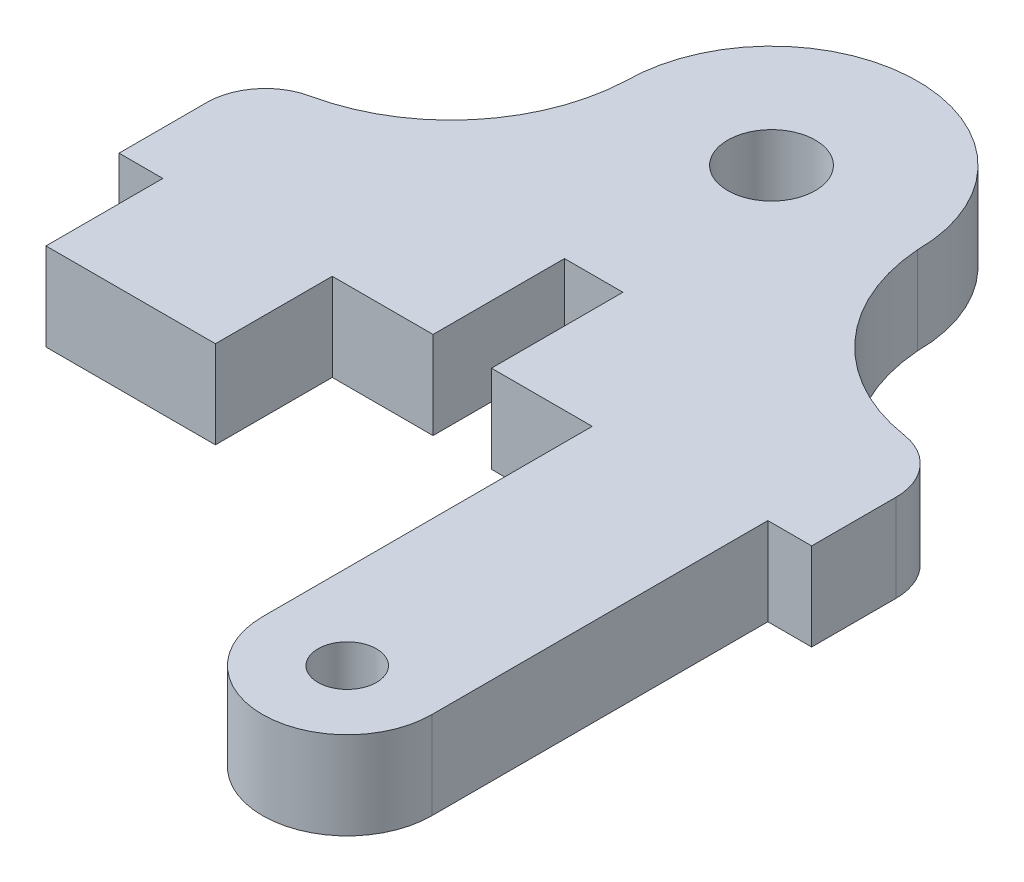
from build123d import *

# Parameters (mm, degrees)
BOSS_EXTRUDE1_DEPTH = 3
SKETCH3_R           = 1.5
CUT_EXTRUDE1_DEPTH  = 3
FILLET1_R           = 2
SKETCH4_R           = 1
CUT_EXTRUDE2_DEPTH  = 10


with BuildPart() as part:
    # Sketch2 → Boss-Extrude1 (new body)
    with BuildSketch(Plane(origin=(0, 0, 0), x_dir=(1, 0, 0), z_dir=(0, 1, 0))):
        with BuildLine():
            Line((4.668611776, -14.59443044), (4.668611776, -22.09443044))
            ThreePointArc((4.668611776, -22.09443044), (7.568611776, -24.99443044), (10.468611776, -22.09443044))
            Line((10.468611776, -22.09443044), (10.468611776, -14.59443044))
            Line((10.468611776, -14.59443044), (10.468611776, -10.59443044))
            Line((10.468611776, -10.59443044), (11.968611776, -10.59443044))
            Line((11.968611776, -10.59443044), (11.968611776, -5.761851858))
            ThreePointArc((11.968611776, -5.761851858), (7.254363967, -4.368466387), (5, 0))
            ThreePointArc((5, 0), (0, 5), (-5, 0))
            ThreePointArc((-5, 0), (-7.028472422, -4.339612176), (-11.531388224, -5.973834769))
            Line((-11.531388224, -5.973834769), (-11.531388224, -10.806413351))
            Line((-11.531388224, -10.806413351), (-10.031388224, -10.806413351))
            Line((-10.031388224, -10.806413351), (-10.031388224, -14.806413351))
            Line((-10.031388224, -14.806413351), (-4.231388224, -14.806413351))
            Line((-4.231388224, -14.806413351), (-4.231388224, -10.806413351))
            Line((-4.231388224, -10.806413351), (-0.781388224, -10.806413351))
            Line((-0.781388224, -10.806413351), (-0.781388224, -6.306413351))
            Line((-0.781388224, -6.306413351), (1.218611776, -6.306413351))
            Line((1.218611776, -6.306413351), (1.218611776, -10.806413351))
            Line((1.218611776, -10.806413351), (4.668611776, -10.806413351))
            Line((4.668611776, -10.806413351), (4.668611776, -14.59443044))
        make_face()
    extrude(amount=BOSS_EXTRUDE1_DEPTH)

    # Sketch3 → Cut-Extrude1 (cut)
    with BuildSketch(Plane(origin=(0, 3, 0), x_dir=(1, 0, 0), z_dir=(0, 1, 0))):
        Circle(SKETCH3_R)
    extrude(amount=-CUT_EXTRUDE1_DEPTH, mode=Mode.SUBTRACT)

    # Fillet1
    fillet1_edges = [part.edges().sort_by_distance(p)[0] for p in [
        (-11.531388224, 1.5, 5.973834769),
        (11.968611776, 1.5, 5.761851858),
    ]]
    fillet(fillet1_edges, radius=FILLET1_R)

    # Sketch4 → Cut-Extrude2 (cut)
    with BuildSketch(Plane(origin=(0, 3, 0), x_dir=(1, 0, 0), z_dir=(0, 1, 0))):
        with Locations((7.568611776, -22.09443044)):
            Circle(SKETCH4_R)
    extrude(amount=-CUT_EXTRUDE2_DEPTH, mode=Mode.SUBTRACT)


solid = part.part
